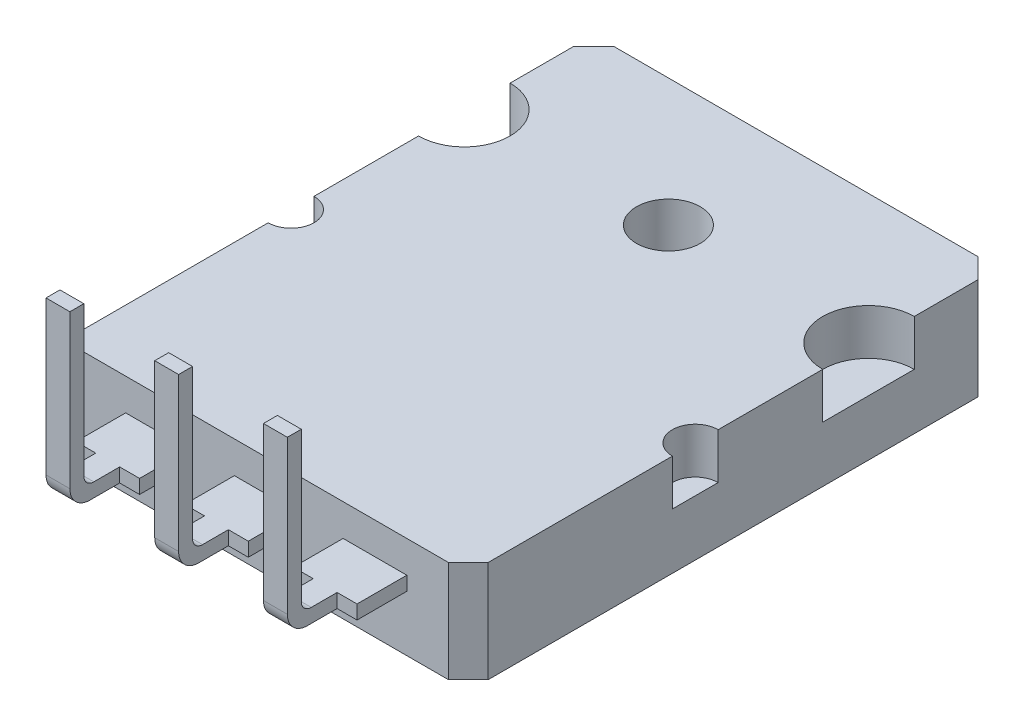
from build123d import *

# Parameters (mm, degrees)
SKETCH_1_W                  = 20.3
SKETCH_1_H                  = 26.6
EXTRUDE_1_DEPTH             = 5.1
SKETCH_2_W                  = 3.2
SKETCH_2_H                  = 0.7
EXTRUDE_2_DEPTH             = 5
SKETCH_3_W                  = 1
SKETCH_3_H                  = 2.5
CUT_EXTRUDE_1_DEPTH         = 22.112851536
SKETCH_4_W                  = 1
SKETCH_4_H                  = 2.5
CUT_EXTRUDE_2_DEPTH         = 22.112851536
SKETCH_5_W                  = 1.2
SKETCH_5_H                  = 0.7
EXTRUDE_3_DEPTH             = 8
SKETCH_6_W                  = 3.2
SKETCH_6_H                  = 0.7
EXTRUDE_4_DEPTH             = 5
SKETCH_7_W                  = 1
SKETCH_7_H                  = 2.5
CUT_EXTRUDE_3_DEPTH         = 23.662799915
SKETCH_8_W                  = 1
SKETCH_8_H                  = 2.5
CUT_EXTRUDE_4_DEPTH         = 23.662799915
SKETCH_9_W                  = 1.2
SKETCH_9_H                  = 0.7
EXTRUDE_5_DEPTH             = 8
SKETCH_10_W                 = 3.2
SKETCH_10_H                 = 0.7
EXTRUDE_6_DEPTH             = 5
SKETCH_11_W                 = 1
SKETCH_11_H                 = 2.5
CUT_EXTRUDE_5_DEPTH         = 23.662799915
SKETCH_12_W                 = 1
SKETCH_12_H                 = 2.5
CUT_EXTRUDE_6_DEPTH         = 23.662799915
SKETCH_13_W                 = 1.2
SKETCH_13_H                 = 0.7
EXTRUDE_7_DEPTH             = 8
HOLE_WIZARD_3_2_3_2_1_D     = 3.2
HOLE_WIZARD_2_3_2_3_1_D     = 2.3
HOLE_WIZARD_2_3_2_3_1_DEPTH = 2.3
HOLE_WIZARD_4_6_4_6_1_D     = 4.6
HOLE_WIZARD_4_6_4_6_1_DEPTH = 2.3
CHAMFER_1_SIZE              = 1
FILLET_1_R                  = 0.5
FILLET_2_R                  = 1
SKETCH_20_R                 = 1.6
CUT_EXTRUDE_7_DEPTH         = 1.5
SKETCH_20_4_R               = 1.6
EXTRUDE_9_DEPTH             = 1.5


with BuildPart() as part:
    # Эскиз1 → Бобышка-Вытянуть1 (new body)
    with BuildSketch(Plane(origin=(0, 2.3, 0), x_dir=(1, 0, 0), z_dir=(0, 1, 0))):
        Rectangle(SKETCH_1_W, SKETCH_1_H)
    extrude(amount=-EXTRUDE_1_DEPTH)

    # Эскиз2 → Бобышка-Вытянуть2 (add)
    with BuildSketch(Plane.XY.offset(13.3)):
        with Locations((5.461, 0.35)):
            Rectangle(SKETCH_2_W, SKETCH_2_H)
    extrude(amount=EXTRUDE_2_DEPTH)

    # Эскиз3 → Вырез-Вытянуть1 (cut, through all)
    with BuildSketch(Plane.XZ):
        with Locations((4.361, 17.05)):
            Rectangle(SKETCH_3_W, SKETCH_3_H)
    extrude(amount=-CUT_EXTRUDE_1_DEPTH, mode=Mode.SUBTRACT)

    # Эскиз4 → Вырез-Вытянуть2 (cut, through all)
    with BuildSketch(Plane.XZ):
        with Locations((6.561, 17.05)):
            Rectangle(SKETCH_4_W, SKETCH_4_H)
    extrude(amount=-CUT_EXTRUDE_2_DEPTH, mode=Mode.SUBTRACT)

    # Эскиз5 → Бобышка-Вытянуть3 (add)
    with BuildSketch(Plane(origin=(0, 0.7, 0), x_dir=(-1, 0, 0), z_dir=(0, 1, 0))):
        with Locations((-5.461, 17.95)):
            Rectangle(SKETCH_5_W, SKETCH_5_H)
    extrude(amount=EXTRUDE_3_DEPTH)

    # Эскиз6 → Бобышка-Вытянуть4 (add)
    with BuildSketch(Plane.XY.offset(13.3)):
        with Locations((0, 0.35)):
            Rectangle(SKETCH_6_W, SKETCH_6_H)
    extrude(amount=EXTRUDE_4_DEPTH)

    # Эскиз7 → Вырез-Вытянуть3 (cut, through all)
    with BuildSketch(Plane.XZ):
        with Locations((-1.1, 17.05)):
            Rectangle(SKETCH_7_W, SKETCH_7_H)
    extrude(amount=-CUT_EXTRUDE_3_DEPTH, mode=Mode.SUBTRACT)

    # Эскиз8 → Вырез-Вытянуть4 (cut, through all)
    with BuildSketch(Plane.XZ):
        with Locations((1.1, 17.05)):
            Rectangle(SKETCH_8_W, SKETCH_8_H)
    extrude(amount=-CUT_EXTRUDE_4_DEPTH, mode=Mode.SUBTRACT)

    # Эскиз9 → Бобышка-Вытянуть5 (add)
    with BuildSketch(Plane(origin=(0, 0.7, 0), x_dir=(-1, 0, 0), z_dir=(0, 1, 0))):
        with Locations((0, 17.95)):
            Rectangle(SKETCH_9_W, SKETCH_9_H)
    extrude(amount=EXTRUDE_5_DEPTH)

    # Эскиз10 → Бобышка-Вытянуть6 (add)
    with BuildSketch(Plane.XY.offset(13.3)):
        with Locations((-5.461, 0.35)):
            Rectangle(SKETCH_10_W, SKETCH_10_H)
    extrude(amount=EXTRUDE_6_DEPTH)

    # Эскиз11 → Вырез-Вытянуть5 (cut, through all)
    with BuildSketch(Plane.XZ):
        with Locations((-6.561, 17.05)):
            Rectangle(SKETCH_11_W, SKETCH_11_H)
    extrude(amount=-CUT_EXTRUDE_5_DEPTH, mode=Mode.SUBTRACT)

    # Эскиз12 → Вырез-Вытянуть6 (cut, through all)
    with BuildSketch(Plane.XZ):
        with Locations((-4.361, 17.05)):
            Rectangle(SKETCH_12_W, SKETCH_12_H)
    extrude(amount=-CUT_EXTRUDE_6_DEPTH, mode=Mode.SUBTRACT)

    # Эскиз13 → Бобышка-Вытянуть7 (add)
    with BuildSketch(Plane(origin=(0, 0.7, 0), x_dir=(-1, 0, 0), z_dir=(0, 1, 0))):
        with Locations((5.461, 17.95)):
            Rectangle(SKETCH_13_W, SKETCH_13_H)
    extrude(amount=EXTRUDE_7_DEPTH)

    # Диаметр отверстия Ø3.2 (3.2)1 (through all)
    with Locations(Plane(origin=(0, 2.3, 0), x_dir=(1, 0, 0), z_dir=(0, 1, 0))):
        with Locations((0, 6.9)):
            Hole(HOLE_WIZARD_3_2_3_2_1_D / 2)

    # Диаметр отверстия Ø2.3 (2.3)1
    with Locations(Plane(origin=(0, 2.3, 0), x_dir=(1, 0, 0), z_dir=(0, 1, 0))):
        with Locations((10.15, -1.9), (-10.15, -1.9)):
            Hole(HOLE_WIZARD_2_3_2_3_1_D / 2, depth=HOLE_WIZARD_2_3_2_3_1_DEPTH)

    # Диаметр отверстия Ø4.6 (4.6)1
    with Locations(Plane(origin=(0, 2.3, 0), x_dir=(1, 0, 0), z_dir=(0, 1, 0))):
        with Locations((10.15, 6.8), (-10.15, 6.8)):
            Hole(HOLE_WIZARD_4_6_4_6_1_D / 2, depth=HOLE_WIZARD_4_6_4_6_1_DEPTH)

    # Фаска1
    chamfer_1_edges = [part.edges().sort_by_distance(p)[0] for p in [
        (10.15, -0.25, 13.3),
        (-10.15, -0.25, 13.3),
        (10.15, -0.25, -13.3),
        (-10.15, -0.25, -13.3),
    ]]
    chamfer(chamfer_1_edges, length=CHAMFER_1_SIZE)

    # Скругление1
    fillet_1_edges = [part.edges().sort_by_distance(p)[0] for p in [
        (-5.461, 0.7, 17.6),
        (0, 0.7, 17.6),
        (5.461, 0.7, 17.6),
    ]]
    fillet(fillet_1_edges, radius=FILLET_1_R)

    # Скругление2
    fillet_2_edges = [part.edges().sort_by_distance(p)[0] for p in [
        (0, 0, 18.3),
        (-5.461, 0, 18.3),
        (5.461, 0, 18.3),
    ]]
    fillet(fillet_2_edges, radius=FILLET_2_R)

    # Эскиз20 → Вырез-Вытянуть7 (cut)
    with BuildSketch(Plane.XZ.offset(2.8)):
        Polygon((8.735786438, -12.3), (9.15, -11.885786438), (9.15, 11.885786438), (8.735786438, 12.3), (-8.735786438, 12.3), (-9.15, 11.885786438), (-9.15, -11.885786438), (-8.735786438, -12.3), align=None)
        with Locations((0, -6.9)):
            Circle(SKETCH_20_R, mode=Mode.SUBTRACT)
    extrude(amount=-CUT_EXTRUDE_7_DEPTH, mode=Mode.SUBTRACT)


with BuildPart() as body_2:
    # Эскиз20<4> → Бобышка-Вытянуть9 (new body)
    with BuildSketch(Plane.XZ.offset(2.8)):
        Polygon((8.735786438, -12.3), (9.15, -11.885786438), (9.15, 11.885786438), (8.735786438, 12.3), (-8.735786438, 12.3), (-9.15, 11.885786438), (-9.15, -11.885786438), (-8.735786438, -12.3), align=None)
        with Locations((0, -6.9)):
            Circle(SKETCH_20_4_R, mode=Mode.SUBTRACT)
    extrude(amount=-EXTRUDE_9_DEPTH)


solid = Compound([part.part, body_2.part])
